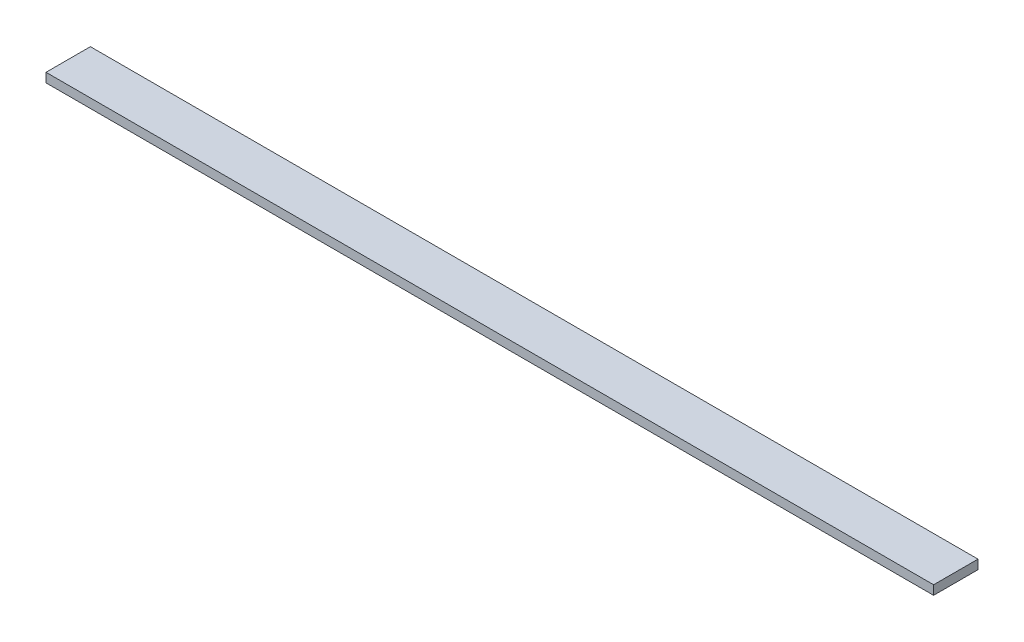
from build123d import *

# Parameters (mm, degrees)
SKETCH1_W           = 7.62
SKETCH1_H           = 152.4
BOSS_EXTRUDE1_DEPTH = 1.5748


with BuildPart() as part:
    # Sketch1 → Boss-Extrude1 (new body)
    with BuildSketch(Plane(origin=(0, 0, 0), x_dir=(0, 0, -1), z_dir=(0, 1, 0))):
        Rectangle(SKETCH1_W, SKETCH1_H)
    extrude(amount=BOSS_EXTRUDE1_DEPTH)


solid = part.part
